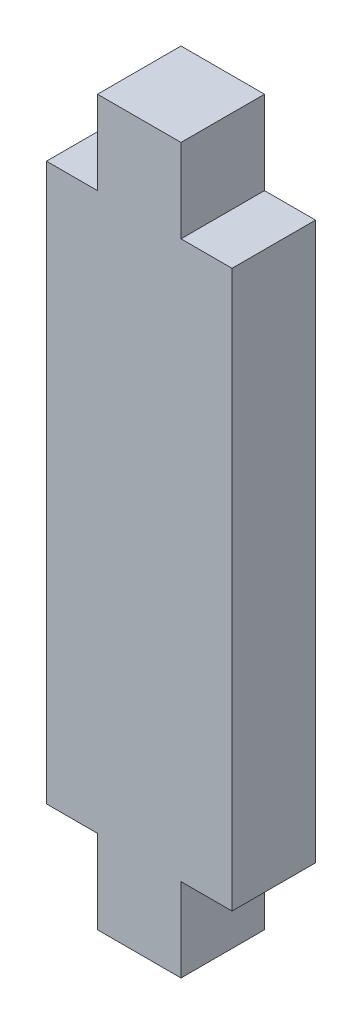
from build123d import *

# Parameters (mm, degrees)
SKETCH2_W           = 4.5
SKETCH2_H           = 4.5
SKETCH2_W_2         = 10
SKETCH2_H_2         = 15
BOSS_EXTRUDE1_DEPTH = 2.25


with BuildPart() as part:
    # Sketch2 → Boss-Extrude1 (new body, symmetric)
    with BuildSketch(Plane.XY):
        with Locations((0, 17.25)):
            Rectangle(SKETCH2_W, SKETCH2_H)
        with Locations((0, 7.5)):
            Rectangle(SKETCH2_W_2, SKETCH2_H_2)
    extrude(amount=BOSS_EXTRUDE1_DEPTH, both=True)

    # Mirror1: part across plane


with BuildPart() as part_1:
    add(part.part)
    add(part.part.mirror(Plane.ZX))


solid = part_1.part
